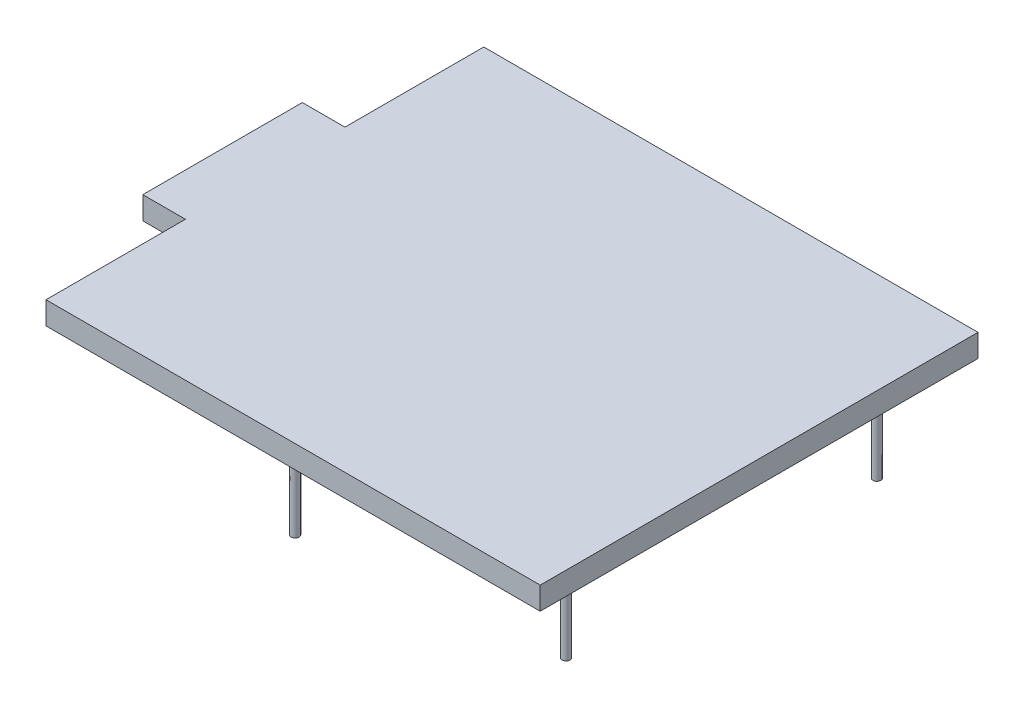
from build123d import *

# Parameters (mm, degrees)
BOSS_EXTRUDE1_DEPTH = 10
SKETCH2_R           = 1.75
BOSS_EXTRUDE2_DEPTH = 40


with BuildPart() as part:
    # Sketch1 → Boss-Extrude1 (new body)
    with BuildSketch(Plane(origin=(0, 0, 0), x_dir=(1, 0, 0), z_dir=(0, 1, 0))):
        Polygon((196.990512748, 28.023652023), (414.922512748, 28.023652023), (414.922512748, -165.016347977), (196.990512748, -165.016347977), (196.990512748, -103.548347977), (178.194512748, -103.548347977), (178.194512748, -33.190347977), (196.990512748, -33.190347977), align=None)
    extrude(amount=BOSS_EXTRUDE1_DEPTH)

    # Sketch2 → Boss-Extrude2 (add)
    with BuildSketch(Plane.XZ):
        with Locations((291.700512748, 149.842465897)):
            Circle(SKETCH2_R)
        with Locations((398.380512748, 137.085232309)):
            Circle(SKETCH2_R)
        with Locations((398.306929068, -0.074747953)):
            Circle(SKETCH2_R)
        with Locations((291.61330246, -12.71751071)):
            Circle(SKETCH2_R)
    extrude(amount=BOSS_EXTRUDE2_DEPTH)


solid = part.part
